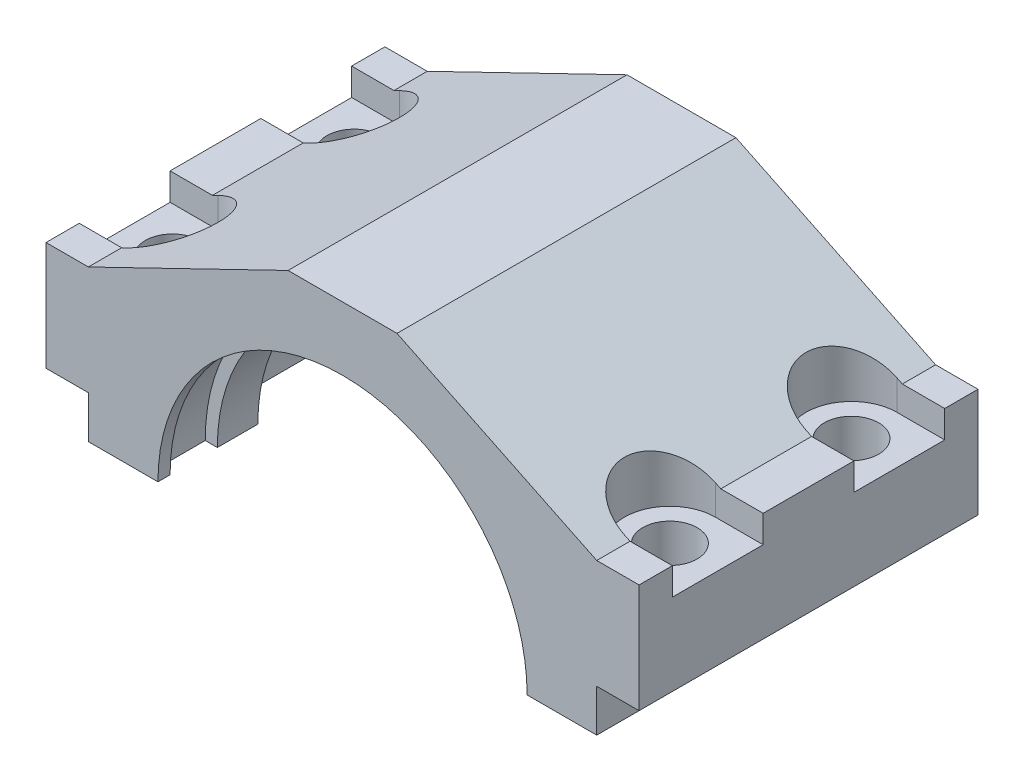
from build123d import *

# Parameters (mm, degrees)
Y_KSEKLIK_EKSTR_ZYON1_DEPTH = 28
KES_EKSTR_ZYON1_DEPTH       = 7.81
KES_EKSTR_ZYON2_DEPTH       = 23
KES_EKSTR_ZYON3_DEPTH       = 9
KES_EKSTR_ZYON4_DEPTH       = 9
KES_EKSTR_ZYON5_START       = -4.5
KES_EKSTR_ZYON5_DEPTH       = 4.5
IZIM7_R                     = 4.5
KES_EKSTR_ZYON6_DEPTH       = 61.043734061


with BuildPart() as part:
    # Çizim1 → Yükseklik-Ekstrüzyon1 (new, symmetric)
    with BuildSketch(Plane.XY):
        with BuildLine():
            Line((9, 0), (-9, 0))
            Line((-9, 0), (-42, -16))
            Line((-42, -16), (-49, -16))
            Line((-49, -16), (-49, -34))
            Line((-49, -34), (-42, -34))
            Line((-42, -34), (-42, -41))
            Line((-42, -41), (-30.5, -41))
            ThreePointArc((-30.5, -41), (0, -10.5), (30.5, -41))
            Line((30.5, -41), (42, -41))
            Line((42, -41), (42, -34))
            Line((42, -34), (49, -34))
            Line((49, -34), (49, -16))
            Line((49, -16), (42, -16))
            Line((42, -16), (9, 0))
        make_face()
    extrude(amount=Y_KSEKLIK_EKSTR_ZYON1_DEPTH, both=True)

    # Çizim2 → Kes-Ekstrüzyon1 (cut)
    with BuildSketch(Plane.XY.offset(26)):
        with BuildLine():
            Line((-32.5, -41), (32.5, -41))
            ThreePointArc((32.5, -41), (0, -8.5), (-32.5, -41))
        make_face()
    extrude(amount=-KES_EKSTR_ZYON1_DEPTH, mode=Mode.SUBTRACT)

    # Çizim3 → Kes-Ekstrüzyon2 (cut)
    with BuildSketch(Plane.XY.offset(11.5)):
        with BuildLine():
            Line((-36, -41), (36, -41))
            ThreePointArc((36, -41), (0, -5), (-36, -41))
        make_face()
    extrude(amount=-KES_EKSTR_ZYON2_DEPTH, mode=Mode.SUBTRACT)

    # Çizim4 → Kes-Ekstrüzyon3 (cut)
    with BuildSketch(Plane.XY.offset(-17)):
        with BuildLine():
            Line((-32.5, -41), (32.5, -41))
            ThreePointArc((32.5, -41), (0, -8.5), (-32.5, -41))
        make_face()
    extrude(amount=-KES_EKSTR_ZYON3_DEPTH, mode=Mode.SUBTRACT)

    # Çizim5 → Kes-Ekstrüzyon4 (cut)
    with BuildSketch(Plane(origin=(0, -16, 0), x_dir=(1, 0, 0), z_dir=(0, 1, 0))):
        with BuildLine():
            Line((41.09, -7.5), (49, -7.5))
            Line((49, -7.5), (49, -22.5))
            Line((49, -22.5), (41.09, -22.5))
            ThreePointArc((41.09, -22.5), (33.59, -15), (41.09, -7.5))
        make_face()
        with BuildLine():
            Line((41.09, 22.5), (49, 22.5))
            Line((49, 22.5), (49, 7.5))
            Line((49, 7.5), (41.09, 7.5))
            ThreePointArc((41.09, 7.5), (33.59, 15), (41.09, 22.5))
        make_face()
    kes_ekstr_zyon4 = extrude(amount=KES_EKSTR_ZYON4_DEPTH, mode=Mode.SUBTRACT)

    # Çizim5<2> → Kes-Ekstrüzyon5 (cut)
    with BuildSketch(Plane(origin=(0, -16, 0), x_dir=(1, 0, 0), z_dir=(0, 1, 0)).offset(KES_EKSTR_ZYON5_START)):
        with BuildLine():
            Line((41.09, -7.5), (49, -7.5))
            Line((49, -7.5), (49, -22.5))
            Line((49, -22.5), (41.09, -22.5))
            ThreePointArc((41.09, -22.5), (33.59, -15), (41.09, -7.5))
        make_face()
        with BuildLine():
            Line((41.09, 22.5), (49, 22.5))
            Line((49, 22.5), (49, 7.5))
            Line((49, 7.5), (41.09, 7.5))
            ThreePointArc((41.09, 7.5), (33.59, 15), (41.09, 22.5))
        make_face()
    kes_ekstr_zyon5 = extrude(amount=KES_EKSTR_ZYON5_DEPTH, mode=Mode.SUBTRACT)

    # Aynalama1: Kes-Ekstrüzyon4, Kes-Ekstrüzyon5 across plane
    add(kes_ekstr_zyon4.mirror(Plane(origin=(0, 0, 0), x_dir=(0, 0, 1), z_dir=(1, 0, 0))), mode=Mode.SUBTRACT)
    add(kes_ekstr_zyon5.mirror(Plane(origin=(0, 0, 0), x_dir=(0, 0, 1), z_dir=(1, 0, 0))), mode=Mode.SUBTRACT)

    # Çizim7 → Kes-Ekstrüzyon6 (cut, through all)
    with BuildSketch(Plane(origin=(0, -20.5, 0), x_dir=(1, 0, 0), z_dir=(0, 1, 0))):
        with Locations((-41.09, -15)):
            Circle(IZIM7_R)
        with Locations((-41.09, 15)):
            Circle(IZIM7_R)
    kes_ekstr_zyon6 = extrude(amount=-KES_EKSTR_ZYON6_DEPTH, mode=Mode.SUBTRACT)

    # Aynalama2: Kes-Ekstrüzyon6 across plane
    add(kes_ekstr_zyon6.mirror(Plane(origin=(0, 0, 0), x_dir=(0, 0, 1), z_dir=(1, 0, 0))), mode=Mode.SUBTRACT)


solid = part.part
